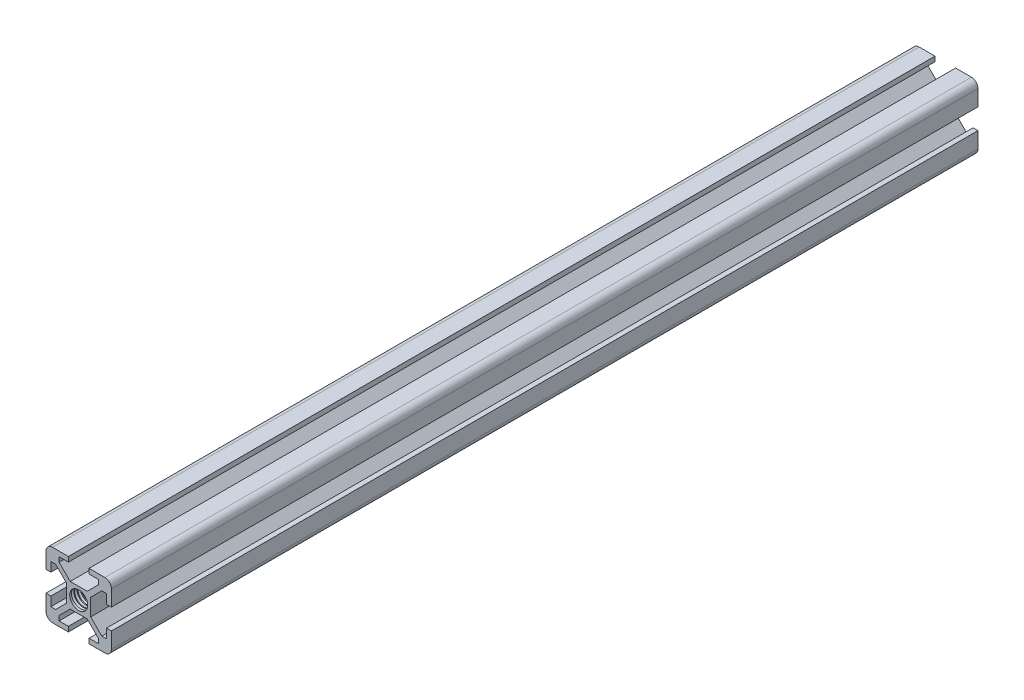
from build123d import *

# Parameters (mm, degrees)
SKETCH1_R           = 2.75
BOSS_EXTRUDE1_DEPTH = 265
CUT_SWEEP2_PITCH    = 1
CUT_SWEEP2_HEIGHT   = 18.5
CUT_SWEEP2_RADIUS   = 2.15


with BuildPart() as part:
    # Sketch1 → Boss-Extrude1 (new body)
    with BuildSketch(Plane.XY):
        with BuildLine():
            Line((-2.599339828, -3.66), (2.599339828, -3.66))
            Line((2.599339828, -3.66), (5.995, -7.055660172))
            Line((5.995, -7.055660172), (5.995, -8.5))
            Line((5.995, -8.5), (3.15, -8.5))
            Line((3.15, -8.5), (3.15, -10))
            Line((3.15, -10), (8, -10))
            ThreePointArc((8, -10), (9.414213562, -9.414213562), (10, -8))
            Line((10, -8), (10, -3.15))
            Line((10, -3.15), (8.5, -3.15))
            Line((8.5, -3.15), (8.5, -5.995))
            Line((8.5, -5.995), (7.055660172, -5.995))
            Line((7.055660172, -5.995), (3.66, -2.599339828))
            Line((3.66, -2.599339828), (3.66, 2.599339828))
            Line((3.66, 2.599339828), (7.055660172, 5.995))
            Line((7.055660172, 5.995), (8.5, 5.995))
            Line((8.5, 5.995), (8.5, 3.15))
            Line((8.5, 3.15), (10, 3.15))
            Line((10, 3.15), (10, 8))
            ThreePointArc((10, 8), (9.414213562, 9.414213562), (8, 10))
            Line((8, 10), (3.15, 10))
            Line((3.15, 10), (3.15, 8.5))
            Line((3.15, 8.5), (5.995, 8.5))
            Line((5.995, 8.5), (5.995, 7.055660172))
            Line((5.995, 7.055660172), (2.599339828, 3.66))
            Line((2.599339828, 3.66), (-2.599339828, 3.66))
            Line((-2.599339828, 3.66), (-5.995, 7.055660172))
            Line((-5.995, 7.055660172), (-5.995, 8.5))
            Line((-5.995, 8.5), (-3.15, 8.5))
            Line((-3.15, 8.5), (-3.15, 10))
            Line((-3.15, 10), (-8, 10))
            ThreePointArc((-8, 10), (-9.414213562, 9.414213562), (-10, 8))
            Line((-10, 8), (-10, 3.15))
            Line((-10, 3.15), (-8.5, 3.15))
            Line((-8.5, 3.15), (-8.5, 5.995))
            Line((-8.5, 5.995), (-7.055660172, 5.995))
            Line((-7.055660172, 5.995), (-3.66, 2.599339828))
            Line((-3.66, 2.599339828), (-3.66, -2.599339828))
            Line((-3.66, -2.599339828), (-7.055660172, -5.995))
            Line((-7.055660172, -5.995), (-8.5, -5.995))
            Line((-8.5, -5.995), (-8.5, -3.15))
            Line((-8.5, -3.15), (-10, -3.15))
            Line((-10, -3.15), (-10, -8))
            ThreePointArc((-10, -8), (-9.414213562, -9.414213562), (-8, -10))
            Line((-8, -10), (-3.15, -10))
            Line((-3.15, -10), (-3.15, -8.5))
            Line((-3.15, -8.5), (-5.995, -8.5))
            Line((-5.995, -8.5), (-5.995, -7.055660172))
            Line((-5.995, -7.055660172), (-2.599339828, -3.66))
        make_face()
        Circle(SKETCH1_R, mode=Mode.SUBTRACT)
    extrude(amount=BOSS_EXTRUDE1_DEPTH)

    # Cut-Sweep2: sweep along a helix
    with BuildLine() as cut_sweep2_path:
        Helix(CUT_SWEEP2_PITCH, CUT_SWEEP2_HEIGHT, CUT_SWEEP2_RADIUS, center=(0, 0, 1), direction=(0, 0, 1))
    # Sketch3 → Cut-Sweep2 (sweep, cut)
    with BuildSketch(Plane(origin=(0, 0, 0), x_dir=(0, 0, -1), z_dir=(1, 0, 0))):
        Polygon((-0.65, 3.389519053), (-1.025, 2.74), (-0.275, 2.74), align=None)
    cut_sweep2 = sweep(path=cut_sweep2_path.line, is_frenet=True, mode=Mode.SUBTRACT)

    # Mirror1: Cut-Sweep2 across plane
    add(cut_sweep2.mirror(Plane(origin=(0, 0, 132.5), x_dir=(1, 0, 0), z_dir=(0, 0, -1))), mode=Mode.SUBTRACT)


solid = part.part
